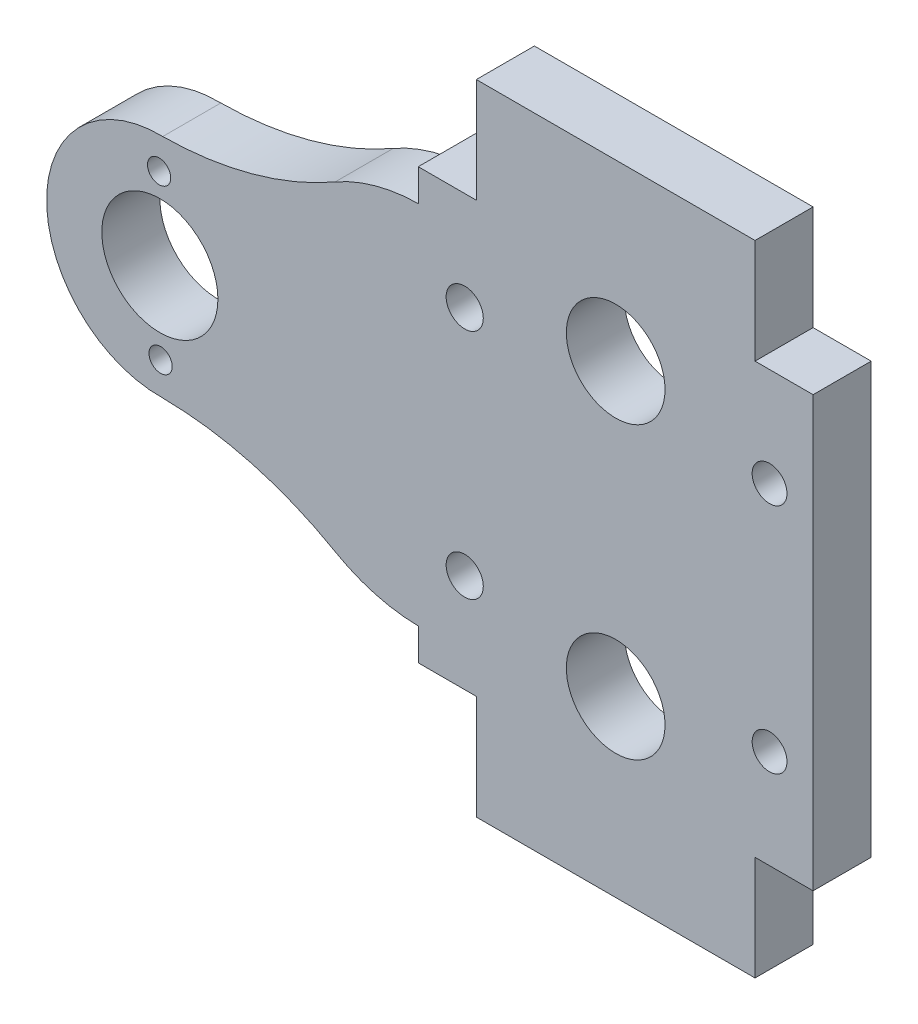
from build123d import *

# Parameters (mm, degrees)
SKETCH1_R           = 1.5
SKETCH1_R_2         = 4.25
SKETCH1_R_3         = 5
SKETCH1_R_4         = 1
BOSS_EXTRUDE2_DEPTH = 5
SKETCH2_W           = 0.5
SKETCH2_H           = 37
BOSS_EXTRUDE3_DEPTH = 5
CUT_EXTRUDE1_DEPTH  = 10
BOSS_EXTRUDE4_DEPTH = 5
SKETCH5_R           = 1.6
CUT_EXTRUDE2_DEPTH  = 10
BOSS_EXTRUDE5_DEPTH = 5
SKETCH7_R           = 1
BOSS_EXTRUDE6_DEPTH = 5


with BuildPart() as part:
    # Sketch1 → Boss-Extrude2 (new body)
    with BuildSketch(Plane.XY):
        with BuildLine():
            Line((45.25091594, -25.207708346), (50.00091594, -20.457708346))
            Line((50.00091594, -20.457708346), (50.00091594, 24.688738263))
            Line((50.00091594, 24.688738263), (45.147362549, 29.542291654))
            Line((45.147362549, 29.542291654), (26.35446933, 29.542291654))
            Line((26.35446933, 29.542291654), (21.25091594, 24.438738263))
            Line((21.25091594, 24.438738263), (21.25091594, 18.042291654))
            Line((21.25091594, 18.042291654), (20.408095363, 18.042291654))
            Line((20.408095363, 18.042291654), (16.70086026, 18.042291654))
            ThreePointArc((16.70086026, 18.042291654), (12.892426636, 17.542145454), (9.3422674, 16.075624987))
            ThreePointArc((9.3422674, 16.075624987), (2.182128173, 13.100539865), (-5.49908406, 12.043324729))
            Line((-5.49908406, 12.043324729), (-5.49908406, 12.039085999))
            ThreePointArc((-5.49908406, 12.039085999), (-15.49908406, 2.292291654), (-5.49908406, -7.454502691))
            Line((-5.49908406, -7.454502691), (-5.49908406, -7.458741422))
            ThreePointArc((-5.49908406, -7.458741422), (2.182128173, -8.515956557), (9.3422674, -11.491041679))
            ThreePointArc((9.3422674, -11.491041679), (12.892426636, -12.957562146), (16.70086026, -13.457708346))
            Line((16.70086026, -13.457708346), (20.408095363, -13.457708346))
            Line((20.408095363, -13.457708346), (21.25091594, -13.457708346))
            Line((21.25091594, -13.457708346), (21.25091594, -20.207708346))
            Line((21.25091594, -20.207708346), (26.25091594, -25.207708346))
            Line((26.25091594, -25.207708346), (45.25091594, -25.207708346))
        make_face()
        with Locations((46.75091594, -7.707708346)):
            Circle(SKETCH1_R, mode=Mode.SUBTRACT)
        with Locations((46.75091594, 12.292291654)):
            Circle(SKETCH1_R, mode=Mode.SUBTRACT)
        with Locations((33.50091594, 14.792291654)):
            Circle(SKETCH1_R_2, mode=Mode.SUBTRACT)
        with Locations((33.50091594, -10.207708346)):
            Circle(SKETCH1_R_2, mode=Mode.SUBTRACT)
        with Locations((19.25091594, 12.292291654)):
            Circle(SKETCH1_R, mode=Mode.SUBTRACT)
        with Locations((19.25091594, -7.707708346)):
            Circle(SKETCH1_R, mode=Mode.SUBTRACT)
        with Locations((-5.74908406, 2.292291654)):
            Circle(SKETCH1_R_3, mode=Mode.SUBTRACT)
        with Locations((1.25091594, 2.354746229)):
            Circle(SKETCH1_R_4, mode=Mode.SUBTRACT)
        with Locations((-5.686629485, -4.707708346)):
            Circle(SKETCH1_R_4, mode=Mode.SUBTRACT)
        with Locations((-12.74908406, 2.229837079)):
            Circle(SKETCH1_R_4, mode=Mode.SUBTRACT)
        with Locations((-5.811538636, 9.292291654)):
            Circle(SKETCH1_R_4, mode=Mode.SUBTRACT)
    extrude(amount=BOSS_EXTRUDE2_DEPTH)

    # Sketch2 → Boss-Extrude3 (add)
    with BuildSketch(Plane(origin=(0, 0, 0), x_dir=(-1, 0, 0), z_dir=(0, 0, -1))):
        Polygon((-26.25091594, -25.207708346), (-21.50091594, -25.207708346), (-21.50091594, -20.457708346), align=None)
        Polygon((-45.25091594, -25.207708346), (-45.50091594, -25.207708346), (-45.50091594, -24.957708346), align=None)
        Polygon((-45.50091594, 29.188738263), (-45.50091594, 29.792291654), (-21.50091594, 29.792291654), (-21.50091594, 24.688738263), (-26.35446933, 29.542291654), (-45.147362549, 29.542291654), align=None)
        with Locations((-50.25091594, 2.292291654)):
            Rectangle(SKETCH2_W, SKETCH2_H)
    extrude(amount=-BOSS_EXTRUDE3_DEPTH)

    # Sketch3 → Cut-Extrude1 (cut)
    with BuildSketch(Plane(origin=(0, 0, 0), x_dir=(-1, 0, 0), z_dir=(0, 0, -1))):
        Polygon((-50.00091594, -16.207708346), (-45.50091594, -16.207708346), (-45.50091594, -25.207708346), (-50.00091594, -20.457708346), align=None)
        Polygon((-50.50091594, 20.792291654), (-45.50091594, 20.792291654), (-45.50091594, 29.188738263), (-50.00091594, 24.688738263), align=None)
        Polygon((-21.50091594, -16.207708346), (-21.50091594, -20.457708346), (-21.25091594, -20.207708346), (-21.25091594, -16.207708346), align=None)
        Polygon((-21.50091594, 20.792291654), (-21.25091594, 20.792291654), (-21.25091594, 24.438738263), (-21.50091594, 24.688738263), align=None)
    extrude(amount=-CUT_EXTRUDE1_DEPTH, mode=Mode.SUBTRACT)

    # Sketch4 → Boss-Extrude4 (add)
    with BuildSketch(Plane(origin=(0, 0, 0), x_dir=(-1, 0, 0), z_dir=(0, 0, -1))):
        with BuildLine():
            Line((-21.25091594, 20.792291654), (-16.50091594, 20.792291654))
            Line((-16.50091594, 20.792291654), (-16.50091594, 18.040936414))
            ThreePointArc((-16.50091594, 18.040936414), (-16.600885803, 18.04195284), (-16.70086026, 18.042291654))
            Line((-16.70086026, 18.042291654), (-21.25091594, 18.042291654))
            Line((-21.25091594, 18.042291654), (-21.25091594, 20.792291654))
        make_face()
        with BuildLine():
            Line((-16.50091594, -13.456353106), (-16.50091594, -16.207708346))
            Line((-16.50091594, -16.207708346), (-21.25091594, -16.207708346))
            Line((-21.25091594, -16.207708346), (-21.25091594, -13.457708346))
            Line((-21.25091594, -13.457708346), (-16.70086026, -13.457708346))
            ThreePointArc((-16.70086026, -13.457708346), (-16.600885803, -13.457369532), (-16.50091594, -13.456353106))
        make_face()
    extrude(amount=-BOSS_EXTRUDE4_DEPTH)

    # Sketch5 → Cut-Extrude2 (cut)
    with BuildSketch(Plane.XY.offset(5)):
        with Locations((20.50091594, -7.707708346)):
            Circle(SKETCH5_R)
        with Locations((20.50091594, 12.292291654)):
            Circle(SKETCH5_R)
    extrude(amount=-CUT_EXTRUDE2_DEPTH, mode=Mode.SUBTRACT)

    # Sketch6 → Boss-Extrude5 (add)
    with BuildSketch(Plane.XY.offset(5)):
        with BuildLine():
            ThreePointArc((19.75191594, -6.293848735), (18.90091594, -7.707708346), (19.75191594, -9.121567957))
            ThreePointArc((19.75191594, -9.121567957), (17.75091594, -7.707708346), (19.75191594, -6.293848735))
        make_face()
        with BuildLine():
            ThreePointArc((19.75191594, 13.706151265), (18.90091594, 12.292291654), (19.75191594, 10.878432043))
            ThreePointArc((19.75191594, 10.878432043), (17.75091594, 12.292291654), (19.75191594, 13.706151265))
        make_face()
    extrude(amount=-BOSS_EXTRUDE5_DEPTH)

    # Sketch7 → Boss-Extrude6 (add)
    with BuildSketch(Plane(origin=(0, 0, 0), x_dir=(-1, 0, 0), z_dir=(0, 0, -1))):
        with Locations((-1.25091594, 2.354746229)):
            Circle(SKETCH7_R)
        with Locations((12.74908406, 2.229837079)):
            Circle(SKETCH7_R)
    extrude(amount=-BOSS_EXTRUDE6_DEPTH)


solid = part.part
